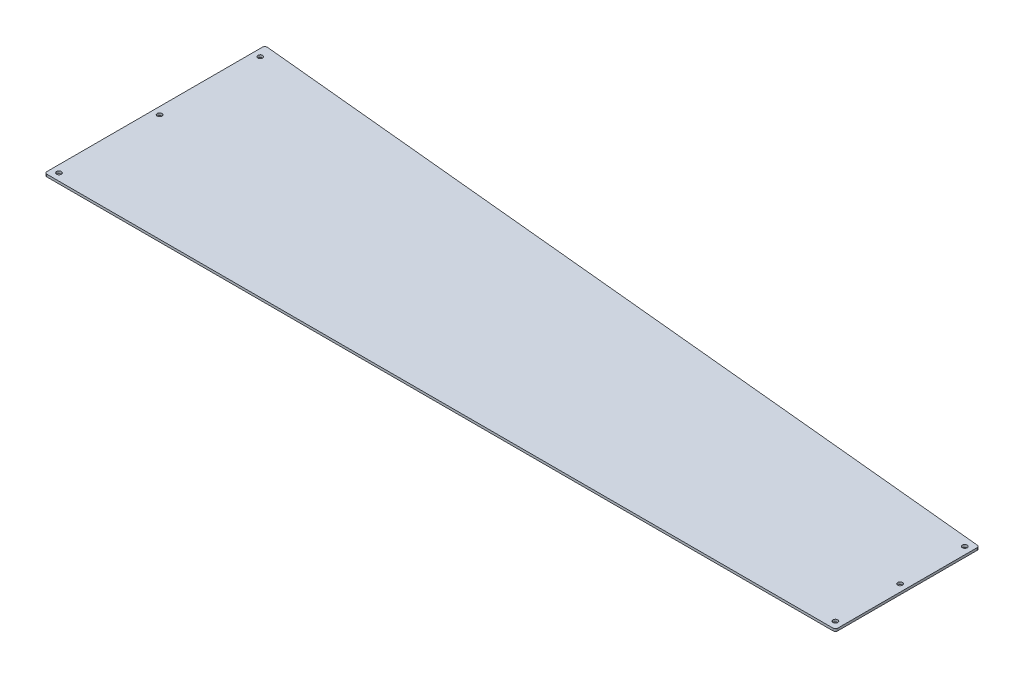
from build123d import *

# Parameters (mm, degrees)
BOSS_EXTRUDE1_DEPTH         = 3.175
FILLET1_R                   = 3.175
F_1_4_0_25_DIAMETER_HOLE1_D = 6.35


with BuildPart() as part:
    # Sketch1 → Boss-Extrude1 (new body)
    with BuildSketch(Plane(origin=(0, 0, 0), x_dir=(1, 0, 0), z_dir=(0, 1, 0))):
        Polygon((-634.164473684, 176.797368421), (413.585526316, 75.197368421), (413.585526316, -115.302631579), (-634.164473684, -115.302631579), align=None)
    extrude(amount=BOSS_EXTRUDE1_DEPTH)

    # Fillet1
    fillet1_edges = [part.edges().sort_by_distance(p)[0] for p in [
        (413.585526316, 1.5875, 115.302631579),
        (-634.164473684, 1.5875, 115.302631579),
        (-634.164473684, 1.5875, -176.797368421),
        (413.585526316, 1.5875, -75.197368421),
    ]]
    fillet(fillet1_edges, radius=FILLET1_R)

    # 1/4 (0.25) Diameter Hole1 (through all)
    with Locations(Plane(origin=(0, 3.175, 0), x_dir=(1, 0, 0), z_dir=(0, 1, 0))):
        with Locations((404.060526316, 65.672368421), (404.060526316, -20.052631579), (404.060526316, -105.777631579), (-624.639473684, -105.777631579), (-624.639473684, 27.572368421), (-624.639473684, 160.922368421)):
            Hole(F_1_4_0_25_DIAMETER_HOLE1_D / 2)


solid = part.part
